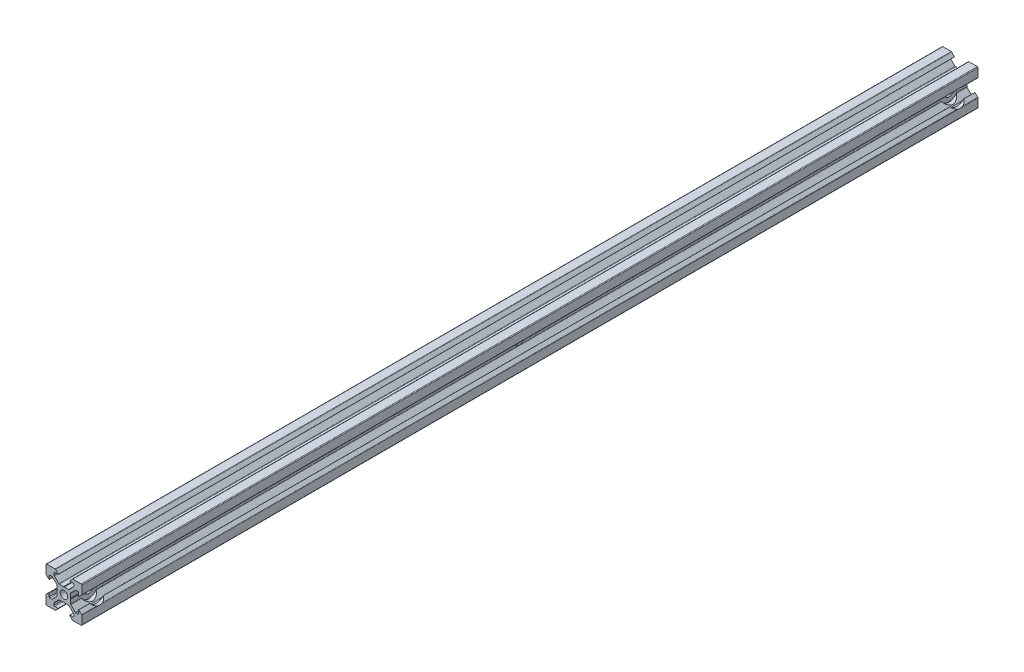
from build123d import *

# Parameters (mm, degrees)
SKETCH_1_R                   = 2
EXTRUDE_1_DEPTH              = 500
HOLE_WIZARD_5_0_5_1_D        = 5
HOLE_WIZARD_10_0_10_1_D      = 10
HOLE_WIZARD_10_0_10_1_DEPTH  = 6.2
HOLE_WIZARD_M5_1_D           = 4.2
HOLE_WIZARD_M5_1_DEPTH       = 10
HOLE_WIZARD_M5_2_D           = 4.2
HOLE_WIZARD_M5_2_DEPTH       = 10
HOLE_WIZARD_M5_3_D           = 4.2
HOLE_WIZARD_M5_3_CSINK_D     = 5.05
HOLE_WIZARD_M5_3_CSINK_ANGLE = 90


with BuildPart() as part:
    # 草图1 → 凸台-拉伸1 (new body)
    with BuildSketch(Plane.XY):
        with BuildLine():
            Line((0.2, 3.8), (2.573654403, 3.8))
            ThreePointArc((2.573654403, 3.8), (2.726727776, 3.830448187), (2.856497116, 3.917157288))
            Line((2.856497116, 3.917157288), (5.382842712, 6.443502884))
            ThreePointArc((5.382842712, 6.443502884), (5.469551813, 6.573272224), (5.5, 6.726345597))
            Line((5.5, 6.726345597), (5.5, 7.8))
            ThreePointArc((5.5, 7.8), (5.382842712, 8.082842712), (5.1, 8.2))
            Line((5.1, 8.2), (3.2, 8.2))
            Line((3.2, 8.2), (3.16812307, 8.273206881))
            Line((3.16812307, 8.273206881), (4.656346981, 9.872492278))
            ThreePointArc((4.656346981, 9.872492278), (4.789482474, 9.966740311), (4.949174504, 10))
            Line((4.949174504, 10), (9.6, 10))
            ThreePointArc((9.6, 10), (9.882842712, 9.882842712), (10, 9.6))
            Line((10, 9.6), (10, 4.949174504))
            ThreePointArc((10, 4.949174504), (9.966740311, 4.789482474), (9.872492278, 4.656346981))
            Line((9.872492278, 4.656346981), (8.273206881, 3.16812307))
            Line((8.273206881, 3.16812307), (8.2, 3.2))
            Line((8.2, 3.2), (8.2, 5.1))
            ThreePointArc((8.2, 5.1), (8.082842712, 5.382842712), (7.8, 5.5))
            Line((7.8, 5.5), (6.726345597, 5.5))
            ThreePointArc((6.726345597, 5.5), (6.573272224, 5.469551813), (6.443502884, 5.382842712))
            Line((6.443502884, 5.382842712), (3.917157288, 2.856497116))
            ThreePointArc((3.917157288, 2.856497116), (3.830448187, 2.726727776), (3.8, 2.573654403))
            Line((3.8, 2.573654403), (3.8, 0.2))
            Line((3.8, 0.2), (3.6, 0))
            Line((3.6, 0), (3.8, -0.2))
            Line((3.8, -0.2), (3.8, -2.573654403))
            ThreePointArc((3.8, -2.573654403), (3.830448187, -2.726727776), (3.917157288, -2.856497116))
            Line((3.917157288, -2.856497116), (6.443502885, -5.382842712))
            ThreePointArc((6.443502885, -5.382842712), (6.573272224, -5.469551813), (6.726345597, -5.5))
            Line((6.726345597, -5.5), (7.8, -5.5))
            ThreePointArc((7.8, -5.5), (8.082842713, -5.382842712), (8.2, -5.1))
            Line((8.2, -5.1), (8.2, -3.2))
            Line((8.2, -3.2), (8.273206881, -3.16812307))
            Line((8.273206881, -3.16812307), (9.872492279, -4.656346981))
            ThreePointArc((9.872492279, -4.656346981), (9.966740311, -4.789482474), (10, -4.949174504))
            Line((10, -4.949174504), (10, -9.6))
            ThreePointArc((10, -9.6), (9.882842713, -9.882842712), (9.6, -10))
            Line((9.6, -10), (4.949174504, -10))
            ThreePointArc((4.949174504, -10), (4.789482475, -9.966740311), (4.656346981, -9.872492278))
            Line((4.656346981, -9.872492278), (3.16812307, -8.273206881))
            Line((3.16812307, -8.273206881), (3.2, -8.2))
            Line((3.2, -8.2), (5.1, -8.2))
            ThreePointArc((5.1, -8.2), (5.382842713, -8.082842712), (5.5, -7.8))
            Line((5.5, -7.8), (5.5, -6.726345597))
            ThreePointArc((5.5, -6.726345597), (5.469551813, -6.573272224), (5.382842713, -6.443502884))
            Line((5.382842713, -6.443502884), (2.856497116, -3.917157288))
            ThreePointArc((2.856497116, -3.917157288), (2.726727777, -3.830448187), (2.573654404, -3.8))
            Line((2.573654404, -3.8), (0.2, -3.8))
            Line((0.2, -3.8), (0, -3.6))
            Line((0, -3.6), (-0.2, -3.8))
            Line((-0.2, -3.8), (-2.573654403, -3.8))
            ThreePointArc((-2.573654403, -3.8), (-2.726727776, -3.830448187), (-2.856497115, -3.917157288))
            Line((-2.856497115, -3.917157288), (-5.382842712, -6.443502885))
            ThreePointArc((-5.382842712, -6.443502885), (-5.469551813, -6.573272224), (-5.5, -6.726345597))
            Line((-5.5, -6.726345597), (-5.5, -7.8))
            ThreePointArc((-5.5, -7.8), (-5.382842712, -8.082842713), (-5.1, -8.2))
            Line((-5.1, -8.2), (-3.2, -8.2))
            Line((-3.2, -8.2), (-3.168123069, -8.273206881))
            Line((-3.168123069, -8.273206881), (-4.656346981, -9.872492279))
            ThreePointArc((-4.656346981, -9.872492279), (-4.789482474, -9.966740311), (-4.949174504, -10))
            Line((-4.949174504, -10), (-9.6, -10))
            ThreePointArc((-9.6, -10), (-9.882842712, -9.882842713), (-10, -9.6))
            Line((-10, -9.6), (-10, -4.949174504))
            ThreePointArc((-10, -4.949174504), (-9.966740311, -4.789482475), (-9.872492278, -4.656346981))
            Line((-9.872492278, -4.656346981), (-8.27320688, -3.16812307))
            Line((-8.27320688, -3.16812307), (-8.2, -3.2))
            Line((-8.2, -3.2), (-8.2, -5.1))
            ThreePointArc((-8.2, -5.1), (-8.082842712, -5.382842713), (-7.8, -5.5))
            Line((-7.8, -5.5), (-6.726345596, -5.5))
            ThreePointArc((-6.726345596, -5.5), (-6.573272223, -5.469551813), (-6.443502884, -5.382842713))
            Line((-6.443502884, -5.382842713), (-3.917157287, -2.856497116))
            ThreePointArc((-3.917157287, -2.856497116), (-3.830448187, -2.726727777), (-3.8, -2.573654404))
            Line((-3.8, -2.573654404), (-3.8, -0.2))
            Line((-3.8, -0.2), (-3.6, 0))
            Line((-3.6, 0), (-3.8, 0.2))
            Line((-3.8, 0.2), (-3.8, 2.573654403))
            ThreePointArc((-3.8, 2.573654403), (-3.830448187, 2.726727776), (-3.917157288, 2.856497115))
            Line((-3.917157288, 2.856497115), (-6.443502884, 5.382842712))
            ThreePointArc((-6.443502884, 5.382842712), (-6.573272224, 5.469551813), (-6.726345597, 5.5))
            Line((-6.726345597, 5.5), (-7.8, 5.5))
            ThreePointArc((-7.8, 5.5), (-8.082842712, 5.382842712), (-8.2, 5.1))
            Line((-8.2, 5.1), (-8.2, 3.2))
            Line((-8.2, 3.2), (-8.273206881, 3.168123069))
            Line((-8.273206881, 3.168123069), (-9.872492278, 4.656346981))
            ThreePointArc((-9.872492278, 4.656346981), (-9.966740311, 4.789482474), (-10, 4.949174504))
            Line((-10, 4.949174504), (-10, 9.6))
            ThreePointArc((-10, 9.6), (-9.882842712, 9.882842712), (-9.6, 10))
            Line((-9.6, 10), (-4.949174504, 10))
            ThreePointArc((-4.949174504, 10), (-4.789482474, 9.966740311), (-4.656346981, 9.872492278))
            Line((-4.656346981, 9.872492278), (-3.16812307, 8.27320688))
            Line((-3.16812307, 8.27320688), (-3.2, 8.2))
            Line((-3.2, 8.2), (-5.1, 8.2))
            ThreePointArc((-5.1, 8.2), (-5.382842712, 8.082842712), (-5.5, 7.8))
            Line((-5.5, 7.8), (-5.5, 6.726345596))
            ThreePointArc((-5.5, 6.726345596), (-5.469551813, 6.573272223), (-5.382842712, 6.443502884))
            Line((-5.382842712, 6.443502884), (-2.856497116, 3.917157287))
            ThreePointArc((-2.856497116, 3.917157287), (-2.726727776, 3.830448187), (-2.573654403, 3.8))
            Line((-2.573654403, 3.8), (-0.2, 3.8))
            Line((-0.2, 3.8), (0, 3.6))
            Line((0, 3.6), (0.2, 3.8))
        make_face()
        Circle(SKETCH_1_R, mode=Mode.SUBTRACT)
    extrude(amount=EXTRUDE_1_DEPTH)

    # Ø5.0 (5) 直径孔1 (through all)
    with Locations(Plane(origin=(10, 0, 0), x_dir=(0, 0, -1), z_dir=(1, 0, 0))):
        with Locations((-490, 0), (-10, 0)):
            Hole(HOLE_WIZARD_5_0_5_1_D / 2)

    # Ø10.0 (10) 直径孔1
    with Locations(Plane(origin=(10, 0, 0), x_dir=(0, 0, -1), z_dir=(1, 0, 0))):
        with Locations((-490, 0), (-10, 0)):
            Hole(HOLE_WIZARD_10_0_10_1_D / 2, depth=HOLE_WIZARD_10_0_10_1_DEPTH)

    # M5 螺纹孔1
    with Locations(Plane(origin=(0, 0, 0), x_dir=(-1, 0, 0), z_dir=(0, 0, -1))):
        with Locations((0, 0)):
            Hole(HOLE_WIZARD_M5_1_D / 2, depth=HOLE_WIZARD_M5_1_DEPTH)

    # M5 螺纹孔2
    with Locations(Plane.XY.offset(500)):
        with Locations((0, 0)):
            Hole(HOLE_WIZARD_M5_2_D / 2, depth=HOLE_WIZARD_M5_2_DEPTH)

    # M5 螺纹孔3 (through all)
    with Locations(Plane(origin=(3.8, 0, 0), x_dir=(0, 0, -1), z_dir=(1, 0, 0))):
        with Locations((-250, 0)):
            CounterSinkHole(HOLE_WIZARD_M5_3_D / 2, HOLE_WIZARD_M5_3_CSINK_D / 2, counter_sink_angle=HOLE_WIZARD_M5_3_CSINK_ANGLE)


solid = part.part
